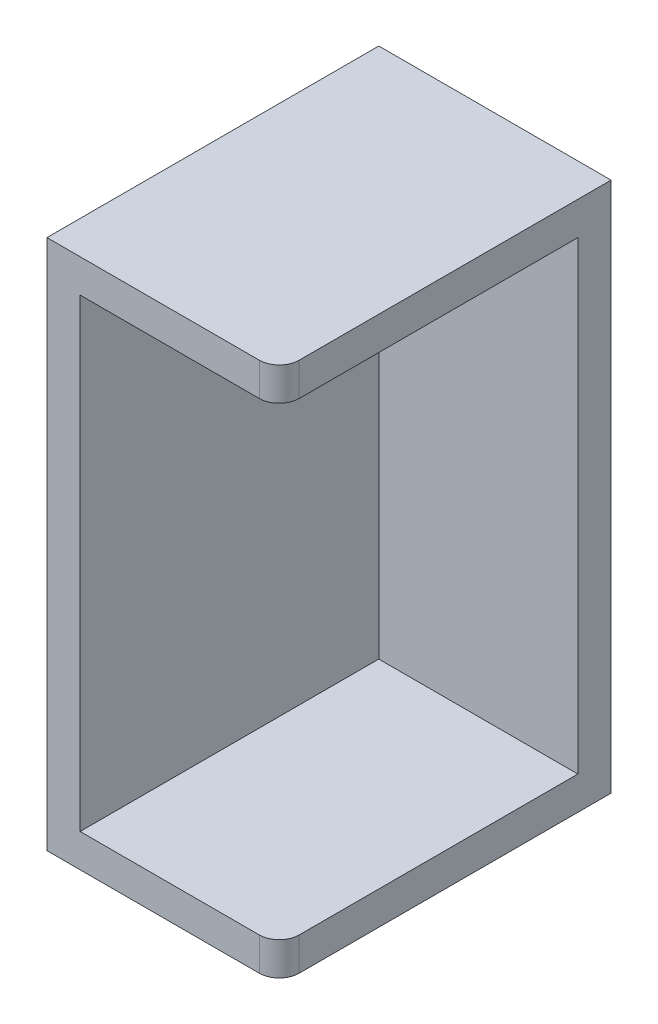
from build123d import *

# Parameters (mm, degrees)
SKETCH_1_W      = 35
SKETCH_1_H      = 80
EXTRUDE_1_DEPTH = 5
EXTRUDE_2_DEPTH = 45
FILLET_1_R      = 3


with BuildPart() as part:
    # 草圖1 → 填料-伸長1 (new body)
    with BuildSketch(Plane.XY):
        with Locations((-18.303993018, -26.708112773)):
            Rectangle(SKETCH_1_W, SKETCH_1_H)
    extrude(amount=EXTRUDE_1_DEPTH)

    # 草圖3 → 填料-伸長2 (add)
    with BuildSketch(Plane.XY.offset(5)):
        Polygon((-35.803993018, 13.291887227), (-35.803993018, -66.708112773), (-0.803993018, -66.708112773), (-0.803993018, -61.708112773), (-30.803993018, -61.708112773), (-30.803993018, 8.291887227), (-0.803993018, 8.291887227), (-0.803993018, 13.291887227), align=None)
    extrude(amount=EXTRUDE_2_DEPTH)

    # 圓角1
    fillet_1_edges = [part.edges().sort_by_distance(p)[0] for p in [
        (-0.803993018, -64.208112773, 50),
        (-0.803993018, 10.791887227, 50),
    ]]
    fillet(fillet_1_edges, radius=FILLET_1_R)


solid = part.part
